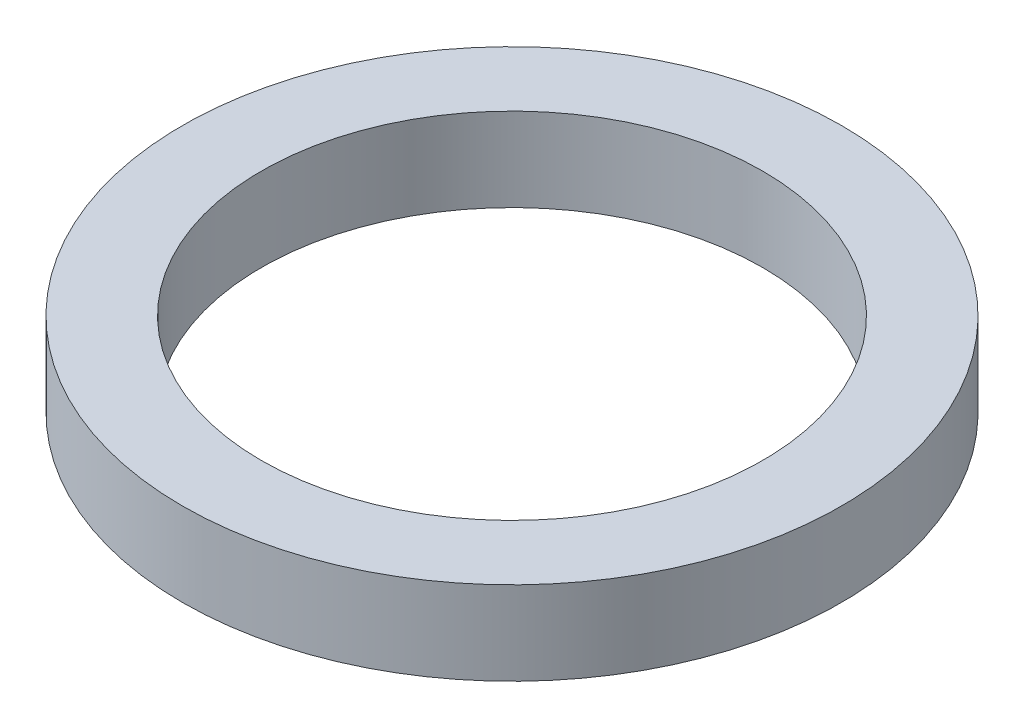
from build123d import *

# Parameters (mm, degrees)
SKETCH1_R           = 6.2611
SKETCH1_R_2         = 4.7625
BOSS_EXTRUDE1_DEPTH = 1.5875


with BuildPart() as part:
    # Sketch1 → Boss-Extrude1 (new body)
    with BuildSketch(Plane(origin=(0, 0, 0), x_dir=(1, 0, 0), z_dir=(0, 1, 0))):
        Circle(SKETCH1_R)
        Circle(SKETCH1_R_2, mode=Mode.SUBTRACT)
    extrude(amount=BOSS_EXTRUDE1_DEPTH)


solid = part.part
